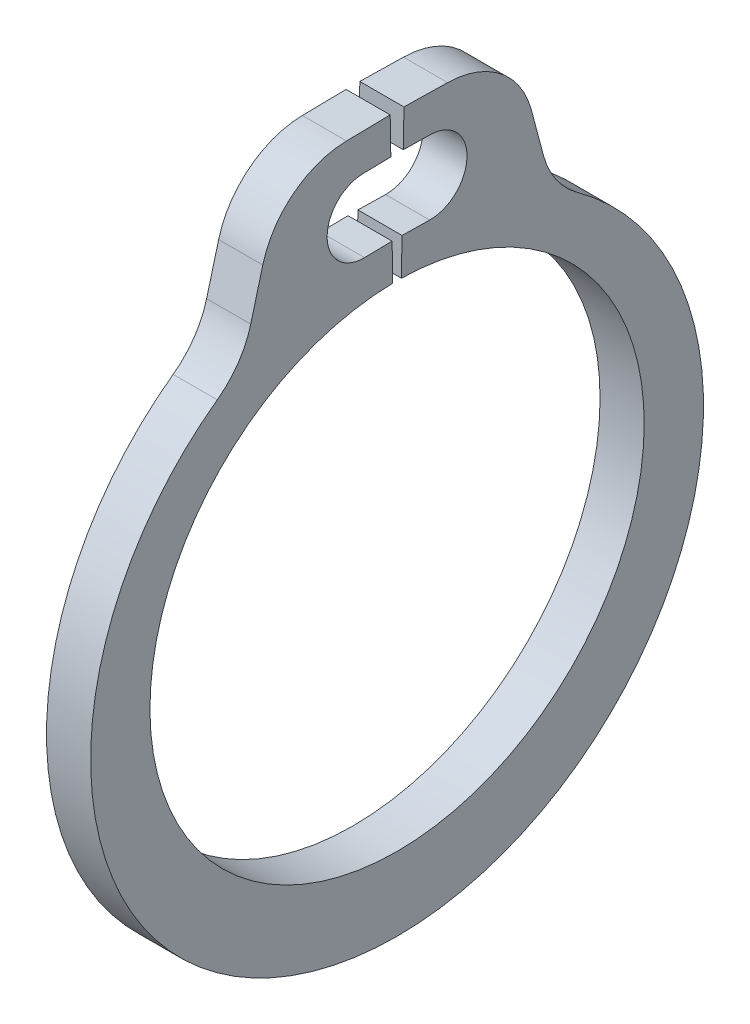
from build123d import *

# Parameters (mm, degrees)
EXTRUDE1_DEPTH = 0.1905
FILLET1_R      = 0.762


with BuildPart() as part:
    # Sketch1 → Extrude1 (new body, symmetric)
    with BuildSketch(Plane(origin=(0, 0, 0), x_dir=(0, 0, -1), z_dir=(1, 0, 0))):
        with BuildLine():
            Line((0.059401011, 3.403081615), (1.01175594, 3.386458198))
            Line((1.01175594, 3.386458198), (1.337932753, 2.159059043))
            ThreePointArc((1.337932753, 2.159059043), (0, -2.7686), (-1.337932753, 2.159059043))
            Line((-1.337932753, 2.159059043), (-1.01175594, 3.386458198))
            Line((-1.01175594, 3.386458198), (-0.059401011, 3.403081615))
            Line((-0.059401011, 3.403081615), (-0.053859872, 3.085629972))
            Line((-0.053859872, 3.085629972), (-0.291948604, 3.081474118))
            ThreePointArc((-0.291948604, 3.081474118), (-0.603859108, 2.758481335), (-0.280866326, 2.446570831))
            Line((-0.280866326, 2.446570831), (-0.042777593, 2.450726686))
            Line((-0.042777593, 2.450726686), (-0.037236454, 2.133275042))
            ThreePointArc((-0.037236454, 2.133275042), (0, -2.1336), (0.037236454, 2.133275042))
            Line((0.037236454, 2.133275042), (0.042777593, 2.450726686))
            Line((0.042777593, 2.450726686), (0.280866326, 2.446570831))
            ThreePointArc((0.280866326, 2.446570831), (0.603859108, 2.758481335), (0.291948604, 3.081474118))
            Line((0.291948604, 3.081474118), (0.053859872, 3.085629972))
            Line((0.053859872, 3.085629972), (0.059401011, 3.403081615))
        make_face()
    extrude(amount=EXTRUDE1_DEPTH, both=True)

    # Fillet1
    fillet1_edges = [part.edges().sort_by_distance(p)[0] for p in [
        (0, 3.386458198, -1.01175594),
        (0, 2.159059043, -1.337932753),
        (0, 2.159059043, 1.337932753),
        (0, 3.386458198, 1.01175594),
    ]]
    fillet(fillet1_edges, radius=FILLET1_R)


solid = part.part
